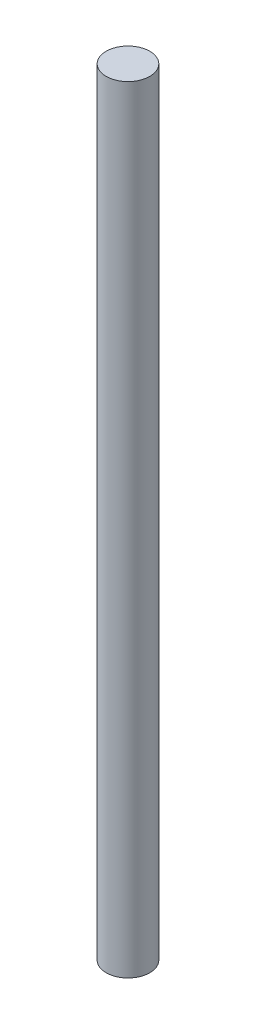
from build123d import *

# Parameters (mm, degrees)
SKETCH1_R           = 3.175
BOSS_EXTRUDE1_DEPTH = 113.03


with BuildPart() as part:
    # Sketch1 → Boss-Extrude1 (new body)
    with BuildSketch(Plane(origin=(0, 0, 0), x_dir=(1, 0, 0), z_dir=(0, 1, 0))):
        Circle(SKETCH1_R)
    extrude(amount=BOSS_EXTRUDE1_DEPTH)


solid = part.part
